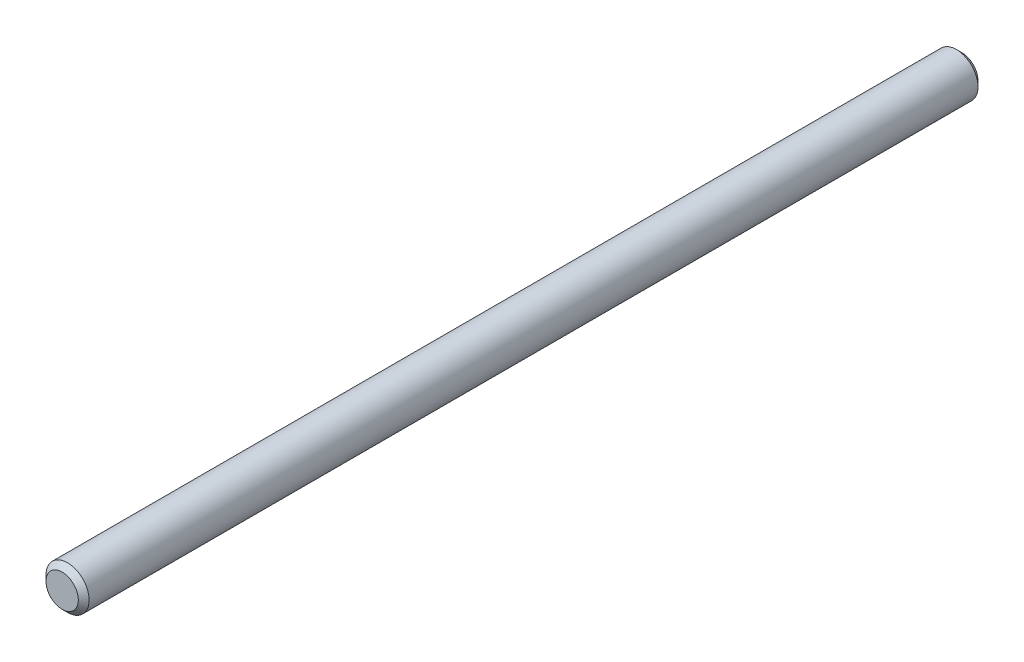
from build123d import *

# Parameters (mm, degrees)
SCHIZZO1_R                   = 4
ESTRUSIONE_ESTRUSIONE1_DEPTH = 167
SMUSSO1_SIZE                 = 1


with BuildPart() as part:
    # Schizzo1 → Estrusione-Estrusione1 (new body)
    with BuildSketch(Plane.XY.offset(64.881229077)):
        Circle(SCHIZZO1_R)
    extrude(amount=ESTRUSIONE_ESTRUSIONE1_DEPTH)

    # Smusso1
    smusso1_edges = [part.edges().sort_by_distance(p)[0] for p in [
        (-4, 0, 64.881229077),
        (-4, 0, 231.881229077),
    ]]
    chamfer(smusso1_edges, length=SMUSSO1_SIZE)


solid = part.part
